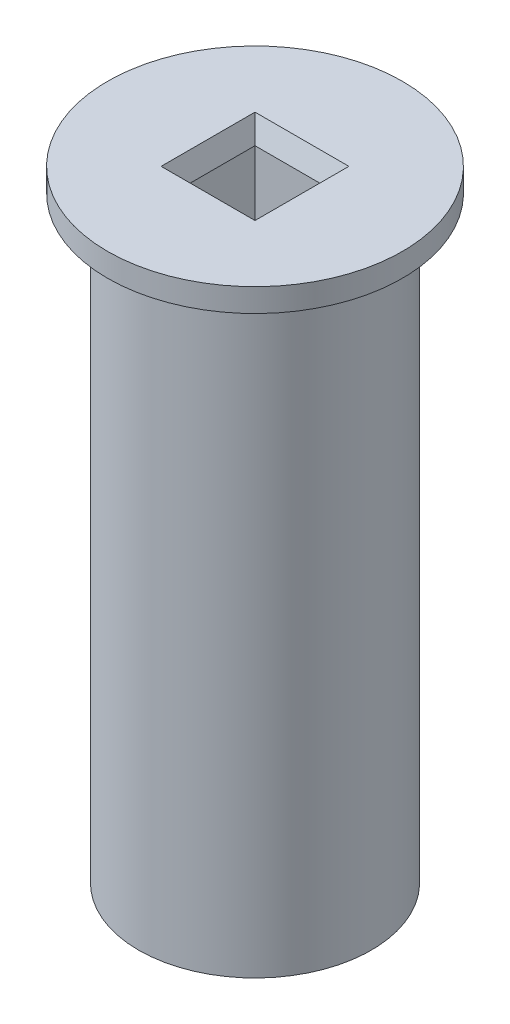
from build123d import *

# Parameters (mm, degrees)
SKETCH_1_R          = 15
SKETCH_1_W          = 10.1
SKETCH_1_H          = 10.1
EXTRUDE_1_DEPTH     = 80
SKETCH1_R           = 19
SKETCH1_W           = 10.1
SKETCH1_H           = 10.1
BOSS_EXTRUDE1_DEPTH = 3
CHAMFER1_SIZE       = 1
CHAMFER1_SIZE2      = 2.747477419


with BuildPart() as part:
    # Эскиз1 → Бобышка-Вытянуть1 (new body)
    with BuildSketch(Plane(origin=(0, 0, 0), x_dir=(1, 0, 0), z_dir=(0, 1, 0))):
        Circle(SKETCH_1_R)
        Rectangle(SKETCH_1_W, SKETCH_1_H, mode=Mode.SUBTRACT)
    extrude(amount=EXTRUDE_1_DEPTH)

    # Sketch1 → Boss-Extrude1 (add)
    with BuildSketch(Plane(origin=(0, 80, 0), x_dir=(1, 0, 0), z_dir=(0, 1, 0))):
        Circle(SKETCH1_R)
        Rectangle(SKETCH1_W, SKETCH1_H, mode=Mode.SUBTRACT)
    extrude(amount=-BOSS_EXTRUDE1_DEPTH)

    # Chamfer1
    chamfer1_edges = [part.edges().sort_by_distance(p)[0] for p in [
        (0, 80, -5.05),
        (-5.05, 80, 0),
        (0, 80, 5.05),
        (5.05, 80, 0),
    ]]
    chamfer1_side = [part.faces().sort_by_distance(p)[0] for p in [
        (-18.462598846, 80, 0),
    ]]
    chamfer(chamfer1_edges, length=CHAMFER1_SIZE, length2=CHAMFER1_SIZE2, reference=chamfer1_side[0])


solid = part.part
